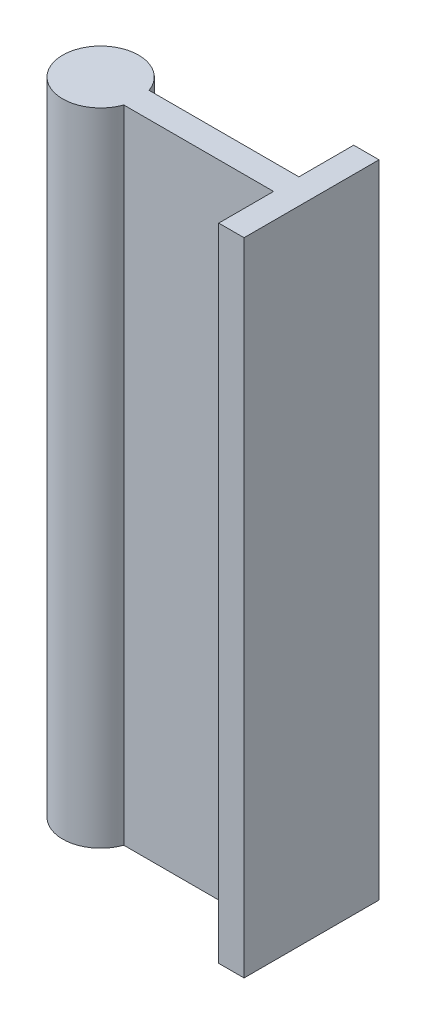
from build123d import *

# Parameters (mm, degrees)
SKETCH_1_R           = 2.25
EXTRUDE_1_DEPTH      = 38
SKETCH_2_W           = 1.5
SKETCH_2_H           = 38
EXTRUDE_2_DEPTH      = 8
EXTRUDE_2_DEPTH_BACK = 3
SKETCH_3_W           = 8
SKETCH_3_H           = 38
EXTRUDE_3_DEPTH      = 1.5


with BuildPart() as part:
    # 草圖1 → 填料-伸長1 (new body)
    with BuildSketch(Plane(origin=(0, 0, 0), x_dir=(1, 0, 0), z_dir=(0, 1, 0))):
        Circle(SKETCH_1_R)
    extrude(amount=EXTRUDE_1_DEPTH)

    # 草圖2 → 填料-伸長2 (add, two sides)
    with BuildSketch(Plane(origin=(3, 0, 0), x_dir=(0, 0, -1), z_dir=(1, 0, 0))) as extrude_2_sk:
        with Locations((0, 19)):
            Rectangle(SKETCH_2_W, SKETCH_2_H)
    extrude(amount=EXTRUDE_2_DEPTH)
    extrude(extrude_2_sk.sketch, amount=-EXTRUDE_2_DEPTH_BACK)

    # 草圖3 → 填料-伸長3 (add)
    with BuildSketch(Plane(origin=(11, 0, 0), x_dir=(0, 0, -1), z_dir=(1, 0, 0))):
        with Locations((0, 19)):
            Rectangle(SKETCH_3_W, SKETCH_3_H)
    extrude(amount=EXTRUDE_3_DEPTH)


solid = part.part
